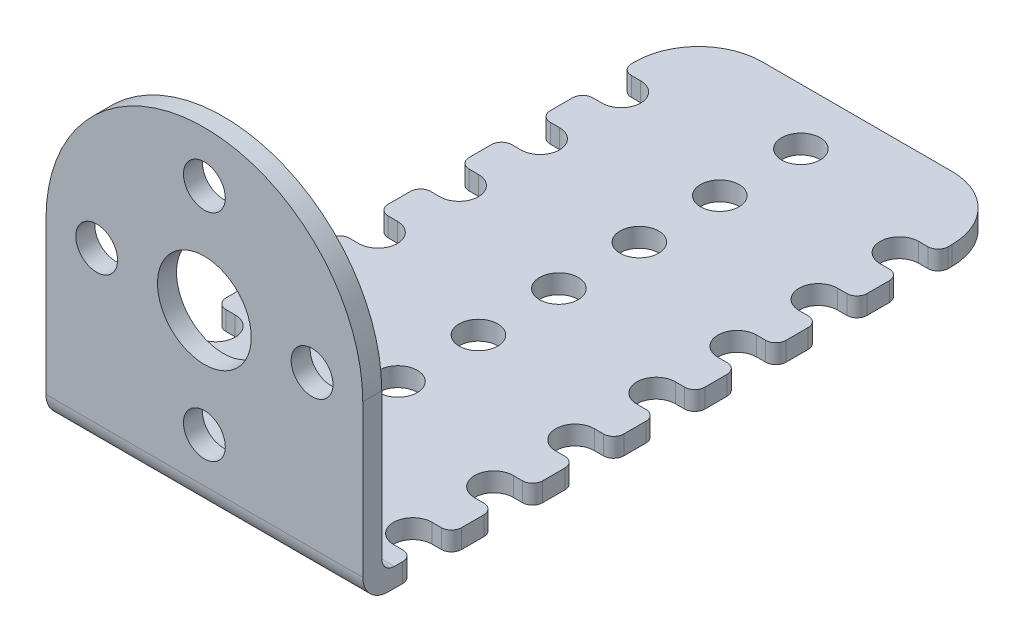
from build123d import *

# Parameters (mm, degrees)
ESBO_O1_W                = 25
ESBO_O1_H                = 51.5
RESSALTO_EXTRUS_O1_DEPTH = 1.5
ESBO_O4_W                = 25
ESBO_O4_H                = 1.5
RESSALTO_EXTRUS_O2_DEPTH = 25
ESBO_O5_R                = 1.65
ESBO_O5_R_2              = 3.7
CORTE_EXTRUS_O1_DEPTH    = 25
ESBO_O7_R                = 1.524
CORTE_EXTRUS_O2_DEPTH    = 25
FILETE1_R                = 5
FILETE2_R                = 2
FILETE3_R                = 1


with BuildPart() as part:
    # Esboço1 → Ressalto-extrusão1 (new body)
    with BuildSketch(Plane(origin=(0, 0, 0), x_dir=(1, 0, 0), z_dir=(0, 1, 0))):
        with Locations((12.5, 25.75)):
            Rectangle(ESBO_O1_W, ESBO_O1_H)
    extrude(amount=RESSALTO_EXTRUS_O1_DEPTH)

    # Esboço4 → Ressalto-extrusão2 (add)
    with BuildSketch(Plane(origin=(0, 1.5, 0), x_dir=(1, 0, 0), z_dir=(0, 1, 0))):
        with Locations((12.5, 0.75)):
            Rectangle(ESBO_O4_W, ESBO_O4_H)
    extrude(amount=RESSALTO_EXTRUS_O2_DEPTH)

    # Esboço5 → Corte-extrusão1 (cut)
    with BuildSketch(Plane.XY):
        with Locations((4, 14)):
            Circle(ESBO_O5_R)
        with BuildLine():
            ThreePointArc((0, 14), (3.661165235, 22.838834765), (12.5, 26.5))
            Line((12.5, 26.5), (0, 26.5))
            Line((0, 26.5), (0, 14))
        make_face()
        with Locations((12.5, 22.5)):
            Circle(ESBO_O5_R)
        with Locations((12.5, 14)):
            Circle(ESBO_O5_R_2)
        with Locations((21, 14)):
            Circle(ESBO_O5_R)
        with Locations((12.5, 5.5)):
            Circle(ESBO_O5_R)
        with BuildLine():
            ThreePointArc((12.5, 26.5), (21.338834765, 22.838834765), (25, 14))
            Line((25, 14), (25, 26.5))
            Line((25, 26.5), (12.5, 26.5))
        make_face()
    extrude(amount=-CORTE_EXTRUS_O1_DEPTH, mode=Mode.SUBTRACT)

    # Esboço7 → Corte-extrusão2 (cut)
    with BuildSketch(Plane(origin=(0, 1.5, 0), x_dir=(1, 0, 0), z_dir=(0, 1, 0))):
        with Locations((12.5, 40.68)):
            Circle(ESBO_O7_R)
        with Locations((12.5, 34.33)):
            Circle(ESBO_O7_R)
        with Locations((12.5, 27.98)):
            Circle(ESBO_O7_R)
        with Locations((12.5, 21.63)):
            Circle(ESBO_O7_R)
        with Locations((12.5, 15.28)):
            Circle(ESBO_O7_R)
        with Locations((12.5, 8.93)):
            Circle(ESBO_O7_R)
        with Locations((12.5, 47.08)):
            Circle(ESBO_O7_R)
        with BuildLine():
            Line((1.524, 3.956), (0.8, 3.956))
            ThreePointArc((0.8, 3.956), (0.234314575, 3.721685425), (0, 3.156))
            Line((0, 3.156), (0, 7.804))
            ThreePointArc((0, 7.804), (0.234314575, 7.238314575), (0.8, 7.004))
            Line((0.8, 7.004), (1.524, 7.004))
            ThreePointArc((1.524, 7.004), (3.048, 5.48), (1.524, 3.956))
        make_face()
        with BuildLine():
            Line((23.476, 45.404), (24.2, 45.404))
            ThreePointArc((24.2, 45.404), (24.765685425, 45.638314575), (25, 46.204))
            Line((25, 46.204), (25, 41.556))
            ThreePointArc((25, 41.556), (24.765685425, 42.121685425), (24.2, 42.356))
            Line((24.2, 42.356), (23.476, 42.356))
            ThreePointArc((23.476, 42.356), (21.952, 43.88), (23.476, 45.404))
        make_face()
        with BuildLine():
            Line((25, 35.156), (25, 39.804))
            ThreePointArc((25, 39.804), (24.765685425, 39.238314575), (24.2, 39.004))
            Line((24.2, 39.004), (23.476, 39.004))
            ThreePointArc((23.476, 39.004), (21.952, 37.48), (23.476, 35.956))
            Line((23.476, 35.956), (24.2, 35.956))
            ThreePointArc((24.2, 35.956), (24.765685425, 35.721685425), (25, 35.156))
        make_face()
        with BuildLine():
            Line((25, 28.756), (25, 33.404))
            ThreePointArc((25, 33.404), (24.765685425, 32.838314575), (24.2, 32.604))
            Line((24.2, 32.604), (23.476, 32.604))
            ThreePointArc((23.476, 32.604), (21.952, 31.08), (23.476, 29.556))
            Line((23.476, 29.556), (24.2, 29.556))
            ThreePointArc((24.2, 29.556), (24.765685425, 29.321685425), (25, 28.756))
        make_face()
        with BuildLine():
            Line((25, 22.356), (25, 27.004))
            ThreePointArc((25, 27.004), (24.765685425, 26.438314575), (24.2, 26.204))
            Line((24.2, 26.204), (23.476, 26.204))
            ThreePointArc((23.476, 26.204), (21.952, 24.68), (23.476, 23.156))
            Line((23.476, 23.156), (24.2, 23.156))
            ThreePointArc((24.2, 23.156), (24.765685425, 22.921685425), (25, 22.356))
        make_face()
        with BuildLine():
            Line((25, 15.956), (25, 20.604))
            ThreePointArc((25, 20.604), (24.765685425, 20.038314575), (24.2, 19.804))
            Line((24.2, 19.804), (23.476, 19.804))
            ThreePointArc((23.476, 19.804), (21.952, 18.28), (23.476, 16.756))
            Line((23.476, 16.756), (24.2, 16.756))
            ThreePointArc((24.2, 16.756), (24.765685425, 16.521685425), (25, 15.956))
        make_face()
        with BuildLine():
            Line((25, 9.556), (25, 14.204))
            ThreePointArc((25, 14.204), (24.765685425, 13.638314575), (24.2, 13.404))
            Line((24.2, 13.404), (23.476, 13.404))
            ThreePointArc((23.476, 13.404), (21.952, 11.88), (23.476, 10.356))
            Line((23.476, 10.356), (24.2, 10.356))
            ThreePointArc((24.2, 10.356), (24.765685425, 10.121685425), (25, 9.556))
        make_face()
        with BuildLine():
            Line((25, 3.156), (25, 7.804))
            ThreePointArc((25, 7.804), (24.765685425, 7.238314575), (24.2, 7.004))
            Line((24.2, 7.004), (23.476, 7.004))
            ThreePointArc((23.476, 7.004), (21.952, 5.48), (23.476, 3.956))
            Line((23.476, 3.956), (24.2, 3.956))
            ThreePointArc((24.2, 3.956), (24.765685425, 3.721685425), (25, 3.156))
        make_face()
        with BuildLine():
            Line((1.524, 10.356), (0.8, 10.356))
            ThreePointArc((0.8, 10.356), (0.234314575, 10.121685425), (0, 9.556))
            Line((0, 9.556), (0, 14.204))
            ThreePointArc((0, 14.204), (0.234314575, 13.638314575), (0.8, 13.404))
            Line((0.8, 13.404), (1.524, 13.404))
            ThreePointArc((1.524, 13.404), (3.048, 11.88), (1.524, 10.356))
        make_face()
        with BuildLine():
            Line((1.524, 16.756), (0.8, 16.756))
            ThreePointArc((0.8, 16.756), (0.234314575, 16.521685425), (0, 15.956))
            Line((0, 15.956), (0, 20.604))
            ThreePointArc((0, 20.604), (0.234314575, 20.038314575), (0.8, 19.804))
            Line((0.8, 19.804), (1.524, 19.804))
            ThreePointArc((1.524, 19.804), (3.048, 18.28), (1.524, 16.756))
        make_face()
        with BuildLine():
            Line((1.524, 23.156), (0.8, 23.156))
            ThreePointArc((0.8, 23.156), (0.234314575, 22.921685425), (0, 22.356))
            Line((0, 22.356), (0, 27.004))
            ThreePointArc((0, 27.004), (0.234314575, 26.438314575), (0.8, 26.204))
            Line((0.8, 26.204), (1.524, 26.204))
            ThreePointArc((1.524, 26.204), (3.048, 24.68), (1.524, 23.156))
        make_face()
        with BuildLine():
            Line((1.524, 29.556), (0.8, 29.556))
            ThreePointArc((0.8, 29.556), (0.234314575, 29.321685425), (0, 28.756))
            Line((0, 28.756), (0, 33.404))
            ThreePointArc((0, 33.404), (0.234314575, 32.838314575), (0.8, 32.604))
            Line((0.8, 32.604), (1.524, 32.604))
            ThreePointArc((1.524, 32.604), (3.048, 31.08), (1.524, 29.556))
        make_face()
        with BuildLine():
            Line((1.524, 35.956), (0.8, 35.956))
            ThreePointArc((0.8, 35.956), (0.234314575, 35.721685425), (0, 35.156))
            Line((0, 35.156), (0, 39.804))
            ThreePointArc((0, 39.804), (0.234314575, 39.238314575), (0.8, 39.004))
            Line((0.8, 39.004), (1.524, 39.004))
            ThreePointArc((1.524, 39.004), (3.048, 37.48), (1.524, 35.956))
        make_face()
        with BuildLine():
            Line((0, 41.556), (0, 46.204))
            ThreePointArc((0, 46.204), (0.234314575, 45.638314575), (0.8, 45.404))
            Line((0.8, 45.404), (1.524, 45.404))
            ThreePointArc((1.524, 45.404), (3.048, 43.88), (1.524, 42.356))
            Line((1.524, 42.356), (0.8, 42.356))
            ThreePointArc((0.8, 42.356), (0.234314575, 42.121685425), (0, 41.556))
        make_face()
    extrude(amount=-CORTE_EXTRUS_O2_DEPTH, mode=Mode.SUBTRACT)

    # Filete1
    filete1_edges = [part.edges().sort_by_distance(p)[0] for p in [
        (0, 0.75, -51.5),
        (25, 0.75, -51.5),
    ]]
    fillet(filete1_edges, radius=FILETE1_R)

    # Filete2
    filete2_edges = [part.edges().sort_by_distance(p)[0] for p in [
        (12.5, 0, 0),
    ]]
    fillet(filete2_edges, radius=FILETE2_R)

    # Filete3
    filete3_edges = [part.edges().sort_by_distance(p)[0] for p in [
        (12.5, 1.5, -1.5),
    ]]
    fillet(filete3_edges, radius=FILETE3_R)


solid = part.part
